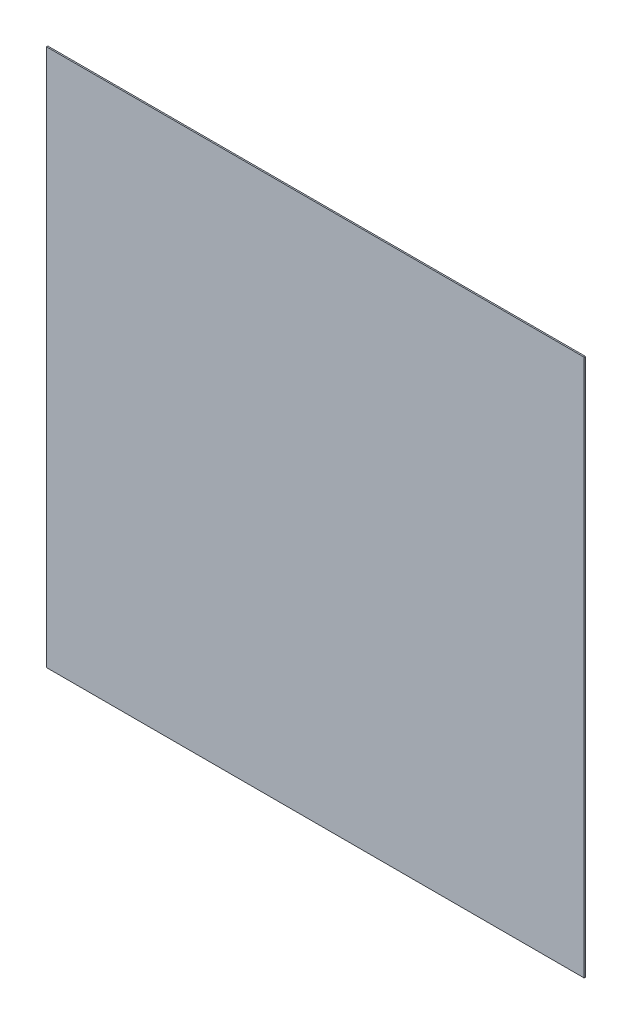
from build123d import *

# Parameters (mm, degrees)
SKETCH1_W           = 400
SKETCH1_H           = 400
BOSS_EXTRUDE1_DEPTH = 1


with BuildPart() as part:
    # Sketch1 → Boss-Extrude1 (new body)
    with BuildSketch(Plane.XY):
        with Locations((200, -200)):
            Rectangle(SKETCH1_W, SKETCH1_H)
    extrude(amount=BOSS_EXTRUDE1_DEPTH)


solid = part.part
